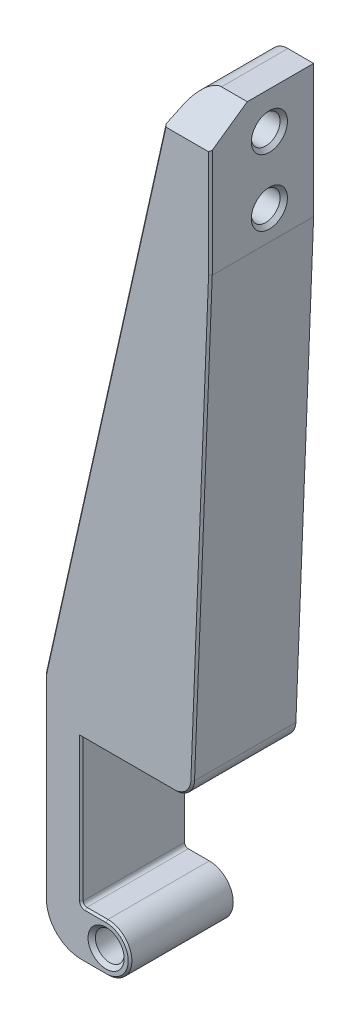
from build123d import *

# Parameters (mm, degrees)
SKETCH1_R           = 3.9
BOSS_EXTRUDE1_DEPTH = 28
SKETCH4_R           = 3.9
CUT_EXTRUDE2_DEPTH  = 10
CUT_EXTRUDE3_DEPTH  = 24
CHAMFER1_SIZE       = 1
CUT_EXTRUDE4_DEPTH  = 46
BOSS_EXTRUDE2_DEPTH = 8
FILLET1_R           = 3
CHAMFER2_SIZE       = 0.5


with BuildPart() as part:
    # Sketch1 → Boss-Extrude1 (new body)
    with BuildSketch(Plane.XY):
        with BuildLine():
            Line((6.7, -39.5), (1, -39.5))
            ThreePointArc((1, -39.5), (0.292893219, -39.207106781), (0, -38.5))
            Line((0, -38.5), (0, 0))
            Line((0, 0), (25.194477487, 0))
            ThreePointArc((25.194477487, 0), (28.659208118, 1.395053169), (30.190545371, 4.801743338))
            Line((30.190545371, 4.801743338), (35, 126))
            Line((35, 126), (35, 162))
            Line((35, 162), (28.005138809, 162))
            ThreePointArc((28.005138809, 162), (24.87921862, 160.902386831), (23.125718898, 158.091449191))
            Line((23.125718898, 158.091449191), (-9.879419911, 10.539063929))
            ThreePointArc((-9.879419911, 10.539063929), (-9.969763553, 9.996659567), (-10, 9.447614738))
            Line((-10, 9.447614738), (-10, -42.5))
            ThreePointArc((-10, -42.5), (-7.071067812, -49.571067812), (0, -52.5))
            Line((0, -52.5), (6.7, -52.5))
            ThreePointArc((6.7, -52.5), (13.2, -46), (6.7, -39.5))
        make_face()
        with Locations((6.7, -46)):
            Circle(SKETCH1_R, mode=Mode.SUBTRACT)
    extrude(amount=BOSS_EXTRUDE1_DEPTH)

    # Sketch4 → Cut-Extrude2 (cut)
    with BuildSketch(Plane(origin=(35, 0, 0), x_dir=(0, 0, -1), z_dir=(1, 0, 0))):
        with Locations((-12, 152)):
            Circle(SKETCH4_R)
        with Locations((-12, 134)):
            Circle(SKETCH4_R)
    extrude(amount=-CUT_EXTRUDE2_DEPTH, mode=Mode.SUBTRACT)

    # Sketch5 → Cut-Extrude3 (cut)
    with BuildSketch(Plane.XY):
        with BuildLine():
            Line((-4.440935128, 16.528028867), (18.877520205, 120.775240942))
            ThreePointArc((18.877520205, 120.775240942), (25.509806245, 125.414980777), (30.728105558, 119.227593919))
            Line((30.728105558, 119.227593919), (26.581075667, 14.722440673))
            ThreePointArc((26.581075667, 14.722440673), (24.437203514, 9.953074436), (19.58658063, 8))
            Line((19.58658063, 8), (2.390252747, 8))
            ThreePointArc((2.390252747, 8), (-3.073088816, 10.623711736), (-4.440935128, 16.528028867))
        make_face()
    extrude(amount=CUT_EXTRUDE3_DEPTH, mode=Mode.SUBTRACT)

    # Chamfer1
    chamfer1_edges = [part.edges().sort_by_distance(p)[0] for p in [
        (2.8, -46, 0),
        (2.8, -46, 28),
        (35, 152, 15.9),
        (35, 134, 15.9),
    ]]
    chamfer(chamfer1_edges, length=CHAMFER1_SIZE)

    # Sketch6 → Cut-Extrude4 (cut, through all)
    with BuildSketch(Plane(origin=(35, 0, 0), x_dir=(0, 0, -1), z_dir=(1, 0, 0))):
        Polygon((-18, 162), (-28, 154.997924618), (-28, 162), align=None)
    extrude(amount=-CUT_EXTRUDE4_DEPTH, mode=Mode.SUBTRACT)

    # Sketch7 → Boss-Extrude2 (add)
    with BuildSketch(Plane(origin=(0, 0, 24), x_dir=(-1, 0, 0), z_dir=(0, 0, -1))):
        with BuildLine():
            Line((-26.7218562, 119.256333807), (-22.401525887, 78.173226899))
            Line((-22.401525887, 78.173226899), (-29.088434109, 77.907873398))
            Line((-29.088434109, 77.907873398), (-28.929828779, 73.911019091))
            Line((-28.929828779, 73.911019091), (-21.982301269, 74.186714627))
            Line((-21.982301269, 74.186714627), (-15.022056754, 8))
            Line((-15.022056754, 8), (-11, 8))
            Line((-11, 8), (-17.976958991, 74.345656781))
            Line((-17.976958991, 74.345656781), (-8.575406865, 74.718734246))
            Line((-8.575406865, 74.718734246), (-9.462969579, 78.686661673))
            Line((-9.462969579, 78.686661673), (-18.396183609, 78.332169052))
            Line((-18.396183609, 78.332169052), (-22.743791996, 119.67467002))
            ThreePointArc((-22.743791996, 119.67467002), (-20.963928, 121.872870229), (-18.765727791, 120.093006233))
            ThreePointArc((-18.765727791, 120.093006233), (-25.360328417, 125.43259822), (-30.699920404, 118.837997594))
            ThreePointArc((-30.699920404, 118.837997594), (-28.920056409, 121.036197803), (-26.7218562, 119.256333807))
        make_face()
    extrude(amount=BOSS_EXTRUDE2_DEPTH)

    # Fillet1
    fillet1_edges = [part.edges().sort_by_distance(p)[0] for p in [
        (21.982301269, 74.186714627, 20),
        (15.022056754, 8, 20),
        (11, 8, 20),
        (17.976958991, 74.345656781, 20),
        (8.575406865, 74.718734246, 20),
        (9.462969579, 78.686661673, 20),
        (18.396183609, 78.332169052, 20),
        (22.401525887, 78.173226899, 20),
        (29.088434109, 77.907873398, 20),
        (28.929828779, 73.911019091, 20),
    ]]
    fillet(fillet1_edges, radius=FILLET1_R)

    # Chamfer2
    chamfer2_edges = [part.edges().sort_by_distance(p)[0] for p in [
        (32.595272685, 65.400871669, 28),
        (35, 140.498962309, 28),
        (-9.969763553, 9.996659567, 28),
        (-10, -16.526192631, 28),
        (-7.071067812, -49.571067812, 28),
        (3.35, -52.5, 28),
        (13.2, -46, 28),
        (12.597238744, 0, 28),
        (3.85, -39.5, 28),
        (0.292893219, -39.207106781, 28),
        (0, -19.25, 28),
        (28.659208118, 1.395053169, 28),
        (6.277163193, 82.768494273, 28),
    ]]
    chamfer(chamfer2_edges, length=CHAMFER2_SIZE)


solid = part.part
